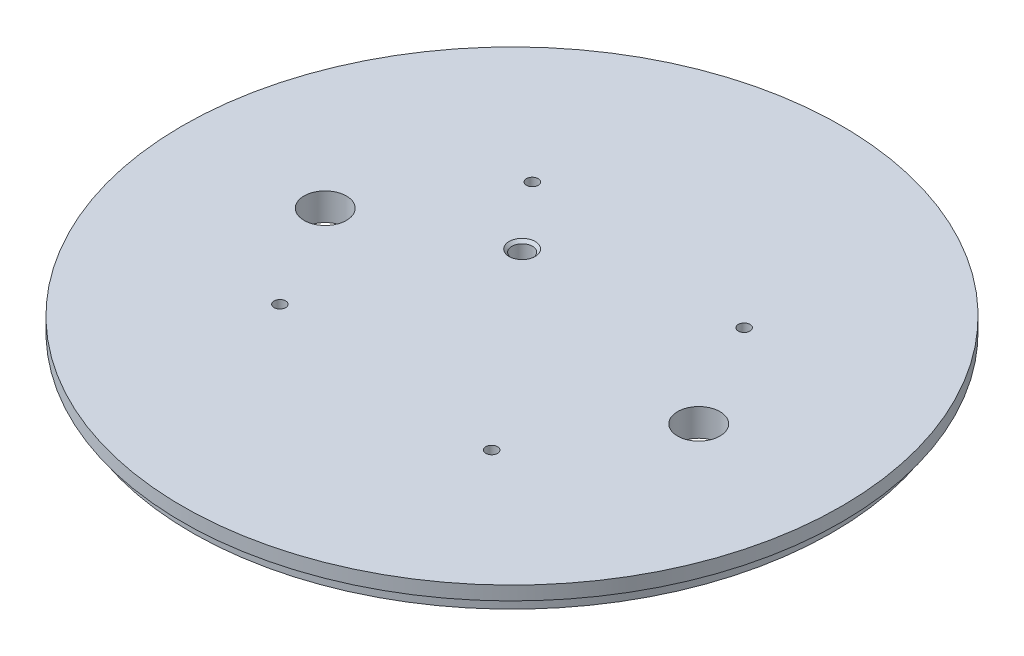
from build123d import *

# Parameters (mm, degrees)
SKETCH1_R                 = 76.2
BOSS_EXTRUDE1_DEPTH       = 6.35
TAP_DRILL_FOR_6_32_TAP1_D = 2.7051
CIRPATTERN1_COUNT         = 4
W_0_386_DIAMETER_HOLE1_D  = 9.8044
CUT_EXTRUDE4_DEPTH        = 3.175
SKETCH15_R                = 76.2
SKETCH15_R_2              = 74.041
CUT_EXTRUDE5_DEPTH        = 3.175
BODY_MOVE_COPY1_ANGLE     = 40


with BuildPart() as part:
    # Sketch1 → Boss-Extrude1 (new body)
    with BuildSketch(Plane(origin=(0, 0, 0), x_dir=(1, 0, 0), z_dir=(0, 1, 0))):
        Circle(SKETCH1_R)
    extrude(amount=BOSS_EXTRUDE1_DEPTH)

    # Tap Drill for #6-32 Tap1 (through all)
    with Locations(Plane(origin=(0, 0, 0), x_dir=(-1, 0, 0), z_dir=(0, -1, 0))):
        with Locations((37.52117539, 6.615995569)):
            tap_drill_for_6_32_tap1 = Hole(TAP_DRILL_FOR_6_32_TAP1_D / 2)

    # CirPattern1: Tap Drill for #6-32 Tap1 ×4 about axis
    cirpattern1_axis = Axis((0, 0, 0), (0, 1, 0))
    for i in range(1, CIRPATTERN1_COUNT):
        add(tap_drill_for_6_32_tap1.rotate(cirpattern1_axis, i * 360 / CIRPATTERN1_COUNT), mode=Mode.SUBTRACT)

    # W (0.386) Diameter Hole1 (through all)
    with Locations(Plane(origin=(0, 0, 0), x_dir=(-1, 0, 0), z_dir=(0, -1, 0))):
        with Locations((-33.077799054, 27.755568986), (33.077799054, -27.755568986)):
            Hole(W_0_386_DIAMETER_HOLE1_D / 2)

    # Sketch11 → 3/16 (0.1875) Diameter Hole1 (revolve, cut)
    with BuildSketch(Plane(origin=(-18.760587695, 0, -3.307997785), x_dir=(0, 0, -1), z_dir=(1, 0, 0))):
        Polygon((0, 0), (0, 6.35), (3.01625, 6.35), (2.38125, 5.715), (2.38125, 0.635), (3.01625, 0), align=None)
    revolve(axis=Axis((-18.760587695, -6.35, -3.307997785), (0, 1, 0)), mode=Mode.SUBTRACT)

    # Sketch12 → Cut-Extrude4 (cut)
    with BuildSketch(Plane.XZ):
        with BuildLine():
            ThreePointArc((24.848558171, 24.575146858), (20.286055568, 24.175979603), (19.886888313, 28.738482206))
            Line((19.886888313, 28.738482206), (6.498907978, 12.783308544))
            ThreePointArc((6.498907978, 12.783308544), (10.087375141, 13.744835423), (12.218242907, 10.70164087))
            ThreePointArc((12.218242907, 10.70164087), (12.02293746, 9.594008636), (11.460577836, 8.619973196))
            Line((11.460577836, 8.619973196), (24.848558171, 24.575146858))
        make_face()
        with BuildLine():
            ThreePointArc((25.606223242, 26.656814532), (23.475355476, 29.700009084), (19.886888313, 28.738482206))
            Line((19.886888313, 28.738482206), (24.848558171, 24.575146858))
            ThreePointArc((24.848558171, 24.575146858), (25.410917794, 25.549182297), (25.606223242, 26.656814532))
        make_face()
        with BuildLine():
            Line((24.848558171, 24.575146858), (19.886888313, 28.738482206))
            ThreePointArc((19.886888313, 28.738482206), (20.286055568, 24.175979603), (24.848558171, 24.575146858))
        make_face()
        with BuildLine():
            ThreePointArc((12.218242907, 10.70164087), (10.087375141, 13.744835423), (6.498907978, 12.783308544))
            Line((6.498907978, 12.783308544), (11.460577836, 8.619973196))
            ThreePointArc((11.460577836, 8.619973196), (12.02293746, 9.594008636), (12.218242907, 10.70164087))
        make_face()
        with BuildLine():
            Line((11.460577836, 8.619973196), (6.498907978, 12.783308544))
            ThreePointArc((6.498907978, 12.783308544), (6.898075233, 8.220805941), (11.460577836, 8.619973196))
        make_face()
    cut_extrude4 = extrude(amount=-CUT_EXTRUDE4_DEPTH, mode=Mode.SUBTRACT)

    # Mirror1: Cut-Extrude4 across plane
    add(cut_extrude4.mirror(Plane(origin=(0, 0, 0), x_dir=(-0.766044443, 0, 0.64278761), z_dir=(0.64278761, 0, 0.766044443))), mode=Mode.SUBTRACT)

    # Sketch15 → Cut-Extrude5 (cut)
    with BuildSketch(Plane.XZ):
        Circle(SKETCH15_R)
        Circle(SKETCH15_R_2, mode=Mode.SUBTRACT)
    extrude(amount=-CUT_EXTRUDE5_DEPTH, mode=Mode.SUBTRACT)


with BuildPart() as part_1:
    # Body-Move/Copy1: moved
    add(part.part.rotate(Axis((0, 0, 0), (0, -1, 0)), BODY_MOVE_COPY1_ANGLE))


solid = part_1.part
